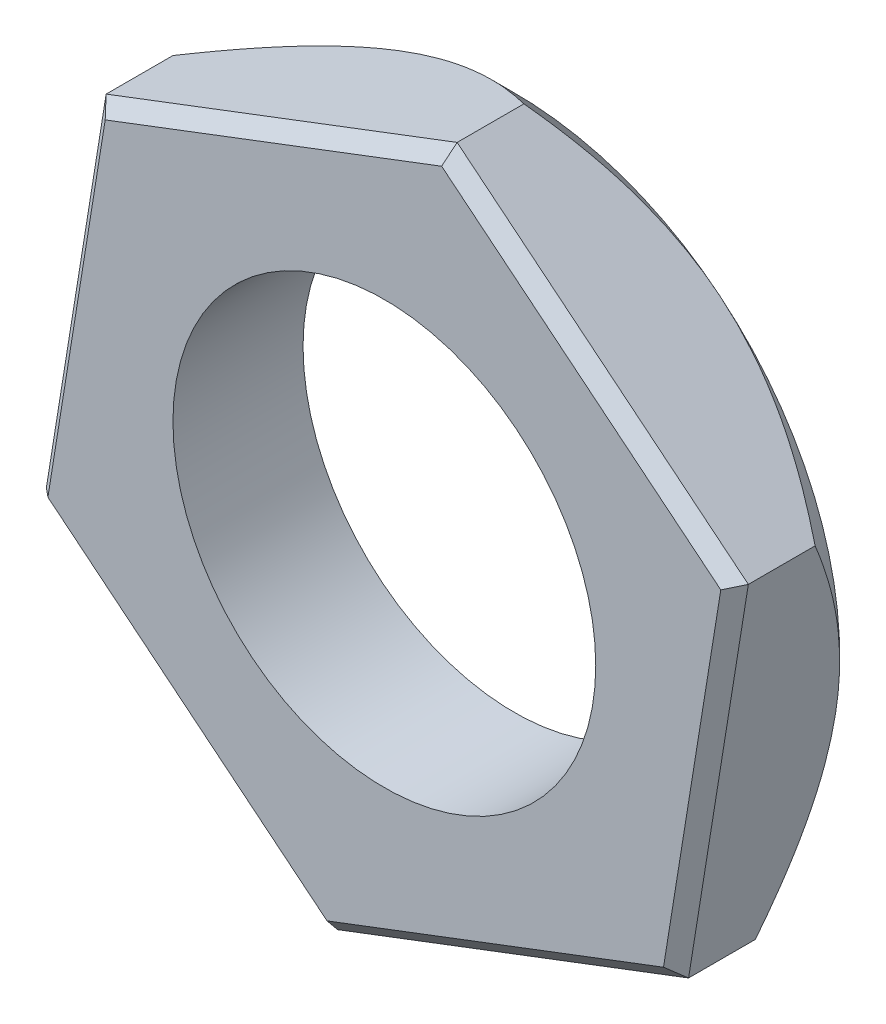
from build123d import *

# Parameters (mm, degrees)
CROQUIS1_R              = 3.25
SALIENTE_EXTRUIR1_DEPTH = 2
CROQUIS2_OUTSIDE_W      = 17.956
CROQUIS2_OUTSIDE_H      = 18.564
CROQUIS2_OUTSIDE_R      = 5
CORTAR_EXTRUIR1_DEPTH   = 1
CORTAR_EXTRUIR1_TAPER   = 45
CHAFL_N2_SIZE           = 0.2
CHAFL_N2_SIZE2          = 0.207106063
CHAFL_N2_PART_2_SIZE    = 0.2
CHAFL_N2_PART_2_SIZE2   = 0.207106063
CHAFL_N2_PART_3_SIZE    = 0.2
CHAFL_N2_PART_3_SIZE2   = 0.207106063
CHAFL_N2_PART_4_SIZE    = 0.2
CHAFL_N2_PART_4_SIZE2   = 0.207106063
CHAFL_N2_PART_5_SIZE    = 0.2
CHAFL_N2_PART_5_SIZE2   = 0.207106063
CHAFL_N2_PART_6_SIZE    = 0.2
CHAFL_N2_PART_6_SIZE2   = 0.207106063


with BuildPart() as part:
    # Croquis1 → Saliente-Extruir1 (new body)
    with BuildSketch(Plane.XY):
        Polygon((-5.395674006, -2.054272462), (-0.918784865, -5.699926991), (4.476889142, -3.645654529), (5.395674006, 2.054272462), (0.918784865, 5.699926991), (-4.476889142, 3.645654529), align=None)
        Circle(CROQUIS1_R, mode=Mode.SUBTRACT)
    extrude(amount=SALIENTE_EXTRUIR1_DEPTH)

    # Croquis2 outside → Cortar-Extruir1 (cut)
    with BuildSketch(Plane(origin=(0, 0, 0), x_dir=(-1, 0, 0), z_dir=(0, 0, -1))):
        Rectangle(CROQUIS2_OUTSIDE_W, CROQUIS2_OUTSIDE_H)
        Circle(CROQUIS2_OUTSIDE_R, mode=Mode.SUBTRACT)
    extrude(amount=-CORTAR_EXTRUIR1_DEPTH, taper=CORTAR_EXTRUIR1_TAPER, mode=Mode.SUBTRACT)

    # Chaflán2
    chafl_n2_edges = [part.edges().sort_by_distance(p)[0] for p in [
        (1.779052139, -4.67279076, 2),
    ]]
    chafl_n2_side = [part.faces().sort_by_distance(p)[0] for p in [
        (1.779052139, -4.67279076, 1.117030845),
    ]]
    chamfer(chafl_n2_edges, length=CHAFL_N2_SIZE, length2=CHAFL_N2_SIZE2, reference=chafl_n2_side[0])

    # Chaflán2 part 2
    chafl_n2_part_2_edges = [part.edges().sort_by_distance(p)[0] for p in [
        (4.936281574, -0.795691033, 2),
    ]]
    chafl_n2_part_2_side = [part.faces().sort_by_distance(p)[0] for p in [
        (4.936281574, -0.795691033, 1.117030845),
    ]]
    chamfer(chafl_n2_part_2_edges, length=CHAFL_N2_PART_2_SIZE, length2=CHAFL_N2_PART_2_SIZE2, reference=chafl_n2_part_2_side[0])

    # Chaflán2 part 3
    chafl_n2_part_3_edges = [part.edges().sort_by_distance(p)[0] for p in [
        (3.157229436, 3.877099727, 2),
    ]]
    chafl_n2_part_3_side = [part.faces().sort_by_distance(p)[0] for p in [
        (3.157229436, 3.877099727, 1.117030845),
    ]]
    chamfer(chafl_n2_part_3_edges, length=CHAFL_N2_PART_3_SIZE, length2=CHAFL_N2_PART_3_SIZE2, reference=chafl_n2_part_3_side[0])

    # Chaflán2 part 4
    chafl_n2_part_4_edges = [part.edges().sort_by_distance(p)[0] for p in [
        (-1.779052139, 4.67279076, 2),
    ]]
    chafl_n2_part_4_side = [part.faces().sort_by_distance(p)[0] for p in [
        (-1.779052139, 4.67279076, 1.117030845),
    ]]
    chamfer(chafl_n2_part_4_edges, length=CHAFL_N2_PART_4_SIZE, length2=CHAFL_N2_PART_4_SIZE2, reference=chafl_n2_part_4_side[0])

    # Chaflán2 part 5
    chafl_n2_part_5_edges = [part.edges().sort_by_distance(p)[0] for p in [
        (-4.936281574, 0.795691033, 2),
    ]]
    chafl_n2_part_5_side = [part.faces().sort_by_distance(p)[0] for p in [
        (-4.936281574, 0.795691033, 1.117030845),
    ]]
    chamfer(chafl_n2_part_5_edges, length=CHAFL_N2_PART_5_SIZE, length2=CHAFL_N2_PART_5_SIZE2, reference=chafl_n2_part_5_side[0])

    # Chaflán2 part 6
    chafl_n2_part_6_edges = [part.edges().sort_by_distance(p)[0] for p in [
        (-3.157229436, -3.877099727, 2),
    ]]
    chafl_n2_part_6_side = [part.faces().sort_by_distance(p)[0] for p in [
        (-3.157229436, -3.877099727, 1.117030845),
    ]]
    chamfer(chafl_n2_part_6_edges, length=CHAFL_N2_PART_6_SIZE, length2=CHAFL_N2_PART_6_SIZE2, reference=chafl_n2_part_6_side[0])


solid = part.part
